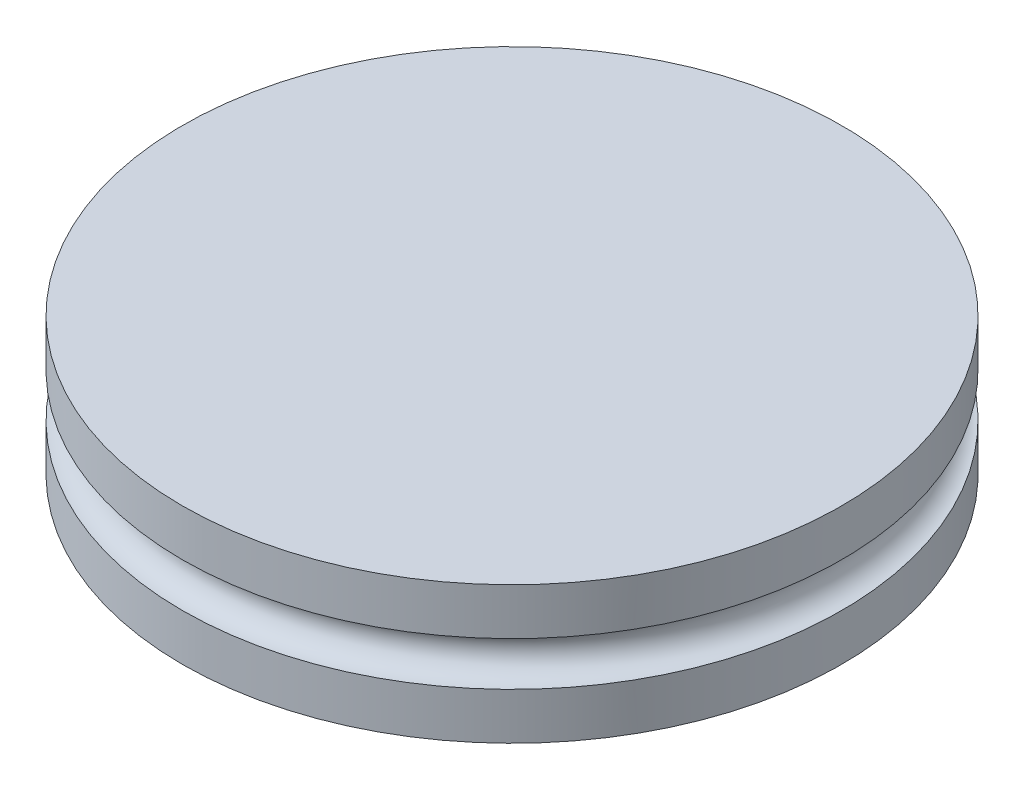
from build123d import *

# Parameters (mm, degrees)
SKETCH1_R           = 7.62
BOSS_EXTRUDE1_DEPTH = 3.175
SKETCH3_R           = 0.508
CUT_EXTRUDE1_DEPTH  = 25.4
SKETCH6_W           = 1.220456994
SKETCH6_H           = 1.016
CUT_EXTRUDE2_DEPTH  = 7.366
SKETCH7_W           = 1.220456994
SKETCH7_H           = 1.016
CUT_EXTRUDE3_DEPTH  = 7.366
SKETCH4_R           = 0.508


with BuildPart() as part:
    # Sketch1 → Boss-Extrude1 (new body)
    with BuildSketch(Plane(origin=(0, 0, 0), x_dir=(1, 0, 0), z_dir=(0, 1, 0))):
        Circle(SKETCH1_R)
    extrude(amount=BOSS_EXTRUDE1_DEPTH)

    # Sketch3 → Cut-Extrude1 (cut, symmetric)
    with BuildSketch(Plane.XY):
        with Locations((-6.604, 1.5875)):
            Circle(SKETCH3_R)
    extrude(amount=CUT_EXTRUDE1_DEPTH, both=True, mode=Mode.SUBTRACT)

    # Sketch6 → Cut-Extrude2 (cut)
    with BuildSketch(Plane.XY.offset(-7.62)):
        with Locations((-7.214228497, 1.5875)):
            Rectangle(SKETCH6_W, SKETCH6_H)
    extrude(amount=CUT_EXTRUDE2_DEPTH, mode=Mode.SUBTRACT)

    # Sketch7 → Cut-Extrude3 (cut)
    with BuildSketch(Plane.XY.offset(7.62)):
        with Locations((-7.214228497, 1.5875)):
            Rectangle(SKETCH7_W, SKETCH7_H)
    extrude(amount=-CUT_EXTRUDE3_DEPTH, mode=Mode.SUBTRACT)

    # Cut-Sweep1: sweep along a path in Sketch5
    with BuildLine(Plane(origin=(0, 0, 0), x_dir=(1, 0, 0), z_dir=(0, 1, 0))) as cut_sweep1_path:
        ThreePointArc((-7.554809844, -0.994609585), (7.62, 0), (-7.554809844, 0.994609585))
    # Sketch4 → Cut-Sweep1 (sweep, cut)
    with BuildSketch(Plane.XY):
        with Locations((7.62, 1.5875)):
            Circle(SKETCH4_R)
    sweep(path=cut_sweep1_path.line, mode=Mode.SUBTRACT)


solid = part.part
